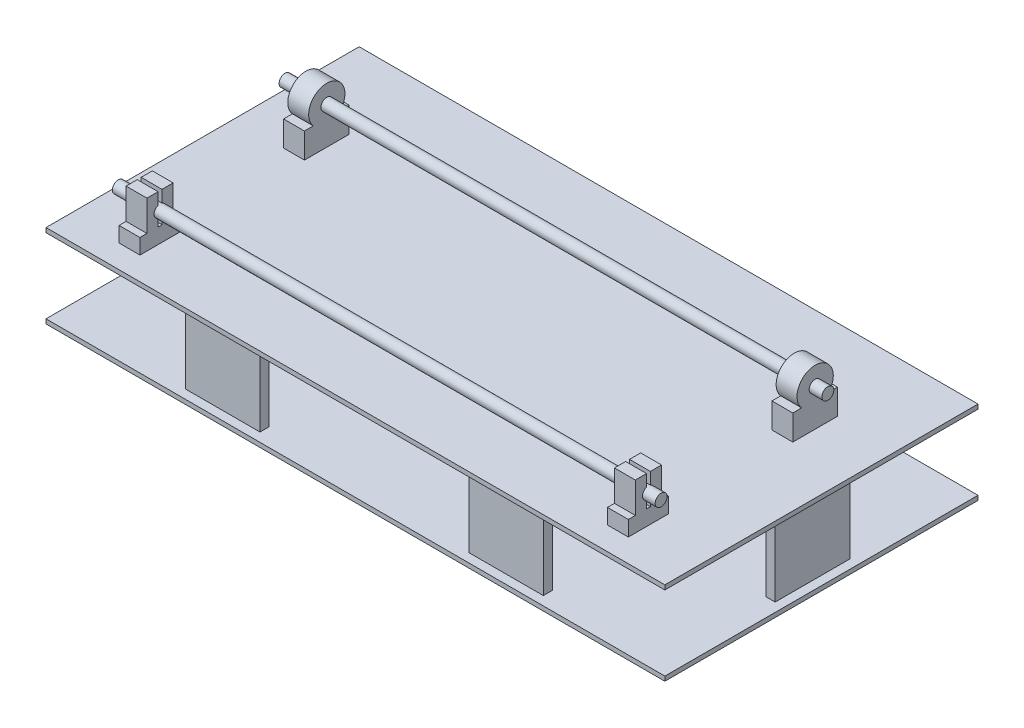
from build123d import *

# Parameters (mm, degrees)
SKETCH2_W           = 415
SKETCH2_H           = 210
BOSS_EXTRUDE1_DEPTH = 3
SKETCH3_W           = 415
SKETCH3_H           = 210
BOSS_EXTRUDE2_DEPTH = 3
BOSS_EXTRUDE3_REACH = 470.118
SKETCH4_W           = 6
SKETCH4_H           = 50
SKETCH4_W_2         = 50
SKETCH4_H_2         = 6
BOSS_EXTRUDE4_DEPTH = 14
SKETCH5_3_R         = 4
BOSS_EXTRUDE5_DEPTH = 350
SKETCH8_R           = 4
BOSS_EXTRUDE6_DEPTH = 14
SKETCH5_4_R         = 4
BOSS_EXTRUDE7_DEPTH = 14


with BuildPart() as part:
    # Sketch2 → Boss-Extrude1 (new body)
    with BuildSketch(Plane(origin=(0, 0, 0), x_dir=(1, 0, 0), z_dir=(0, 1, 0))):
        with Locations((207.5, 105)):
            Rectangle(SKETCH2_W, SKETCH2_H)
    extrude(amount=BOSS_EXTRUDE1_DEPTH)


with BuildPart() as body_2:
    # Sketch3 → Boss-Extrude2 (new body)
    with BuildSketch(Plane(origin=(0, 53, 0), x_dir=(1, 0, 0), z_dir=(0, 1, 0))):
        with Locations((207.5, 105)):
            Rectangle(SKETCH3_W, SKETCH3_H)
    extrude(amount=BOSS_EXTRUDE2_DEPTH)

    # Sketch4 → Boss-Extrude3 (add, up to next)
    with BuildSketch(Plane(origin=(0, 3, 0), x_dir=(1, 0, 0), z_dir=(0, 1, 0)), mode=Mode.PRIVATE) as boss_extrude3_sk1:
        with Locations((9, 105)):
            Rectangle(SKETCH4_W, SKETCH4_H)
    boss_extrude3_tool1 = extrude(boss_extrude3_sk1.sketch, amount=BOSS_EXTRUDE3_REACH, mode=Mode.PRIVATE) - body_2.part
    # Sketch4 → Boss-Extrude3 (add, up to next)
    with BuildSketch(Plane(origin=(0, 3, 0), x_dir=(1, 0, 0), z_dir=(0, 1, 0)), mode=Mode.PRIVATE) as boss_extrude3_sk2:
        with Locations((112.5, 9)):
            Rectangle(SKETCH4_W_2, SKETCH4_H_2)
    boss_extrude3_tool2 = extrude(boss_extrude3_sk2.sketch, amount=BOSS_EXTRUDE3_REACH, mode=Mode.PRIVATE) - body_2.part
    # Sketch4 → Boss-Extrude3 (add, up to next)
    with BuildSketch(Plane(origin=(0, 3, 0), x_dir=(1, 0, 0), z_dir=(0, 1, 0)), mode=Mode.PRIVATE) as boss_extrude3_sk3:
        with Locations((302.5, 9)):
            Rectangle(SKETCH4_W_2, SKETCH4_H_2)
    boss_extrude3_tool3 = extrude(boss_extrude3_sk3.sketch, amount=BOSS_EXTRUDE3_REACH, mode=Mode.PRIVATE) - body_2.part
    # Sketch4 → Boss-Extrude3 (add, up to next)
    with BuildSketch(Plane(origin=(0, 3, 0), x_dir=(1, 0, 0), z_dir=(0, 1, 0)), mode=Mode.PRIVATE) as boss_extrude3_sk4:
        with Locations((406, 105)):
            Rectangle(SKETCH4_W, SKETCH4_H)
    boss_extrude3_tool4 = extrude(boss_extrude3_sk4.sketch, amount=BOSS_EXTRUDE3_REACH, mode=Mode.PRIVATE) - body_2.part
    # Sketch4 → Boss-Extrude3 (add, up to next)
    with BuildSketch(Plane(origin=(0, 3, 0), x_dir=(1, 0, 0), z_dir=(0, 1, 0)), mode=Mode.PRIVATE) as boss_extrude3_sk5:
        with Locations((302.5, 201)):
            Rectangle(SKETCH4_W_2, SKETCH4_H_2)
    boss_extrude3_tool5 = extrude(boss_extrude3_sk5.sketch, amount=BOSS_EXTRUDE3_REACH, mode=Mode.PRIVATE) - body_2.part
    # Sketch4 → Boss-Extrude3 (add, up to next)
    with BuildSketch(Plane(origin=(0, 3, 0), x_dir=(1, 0, 0), z_dir=(0, 1, 0)), mode=Mode.PRIVATE) as boss_extrude3_sk6:
        with Locations((112.5, 201)):
            Rectangle(SKETCH4_W_2, SKETCH4_H_2)
    boss_extrude3_tool6 = extrude(boss_extrude3_sk6.sketch, amount=BOSS_EXTRUDE3_REACH, mode=Mode.PRIVATE) - body_2.part

    add(part.part)  # Boss-Extrude3 merges part
    add(boss_extrude3_tool1.solids().sort_by_distance((9, 3, -105))[0])
    add(boss_extrude3_tool2.solids().sort_by_distance((112.5, 3, -9))[0])
    add(boss_extrude3_tool3.solids().sort_by_distance((302.5, 3, -9))[0])
    add(boss_extrude3_tool4.solids().sort_by_distance((406, 3, -105))[0])
    add(boss_extrude3_tool5.solids().sort_by_distance((302.5, 3, -201))[0])
    add(boss_extrude3_tool6.solids().sort_by_distance((112.5, 3, -201))[0])

    # Sketch5 → Boss-Extrude4 (add)
    with BuildSketch(Plane.ZY.offset(-33.5)):
        with BuildLine():
            Line((-20.2, 66.220460186), (-20.2, 86.719329946))
            Line((-20.2, 86.719329946), (-27.7, 86.719329946))
            Line((-27.7, 86.719329946), (-27.7, 78.782856064))
            ThreePointArc((-27.7, 78.782856064), (-25, 75), (-27.7, 71.217143936))
            Line((-27.7, 71.217143936), (-27.7, 66.220460186))
            Line((-27.7, 66.220460186), (-30.3, 66.220460186))
            Line((-30.3, 66.220460186), (-30.3, 71.217143936))
            ThreePointArc((-30.3, 71.217143936), (-33, 75), (-30.3, 78.782856064))
            Line((-30.3, 78.782856064), (-30.3, 86.780809456))
            Line((-30.3, 86.780809456), (-37.8, 86.780809456))
            Line((-37.8, 86.780809456), (-37.8, 66.220460186))
            Line((-37.8, 66.220460186), (-42.5, 66.220460186))
            Line((-42.5, 66.220460186), (-42.5, 56))
            Line((-42.5, 56), (-15.5, 56))
            Line((-15.5, 56), (-15.5, 66.220460186))
            Line((-15.5, 66.220460186), (-20.2, 66.220460186))
        make_face()
        with BuildLine():
            Line((-149.888097116, 72.9128735), (-155.8, 72.9128735))
            Line((-155.8, 72.9128735), (-155.8, 56))
            Line((-155.8, 56), (-125.8, 56))
            Line((-125.8, 56), (-125.8, 72.9128735))
            Line((-125.8, 72.9128735), (-131.711902884, 72.9128735))
            ThreePointArc((-131.711902884, 72.9128735), (-140.8, 93.165324665), (-149.888097116, 72.9128735))
        make_face()
    extrude(amount=-BOSS_EXTRUDE4_DEPTH)

    # Sketch5_3 → Boss-Extrude5 (add)
    with BuildSketch(Plane.ZY.offset(-33.5)):
        with Locations((-29, 75)):
            Circle(SKETCH5_3_R)
        with Locations((-140.8, 81)):
            Circle(SKETCH5_3_R)
    extrude(amount=-BOSS_EXTRUDE5_DEPTH)

    # Sketch8 → Boss-Extrude6 (add)
    # profile 1 of 2: a face of its own
    with BuildSketch(Plane(origin=(361, 0, 0), x_dir=(0, 0, -1), z_dir=(1, 0, 0))):
        with BuildLine():
            Line((37.8, 66.220460186), (37.8, 86.719329946))
            Line((37.8, 86.719329946), (30.3, 86.719329946))
            Line((30.3, 86.719329946), (30.3, 78.782856064))
            ThreePointArc((30.3, 78.782856064), (33, 75), (30.3, 71.217143936))
            Line((30.3, 71.217143936), (30.3, 66.220460186))
            Line((30.3, 66.220460186), (27.7, 66.220460186))
            Line((27.7, 66.220460186), (27.7, 86.780809456))
            Line((27.7, 86.780809456), (20.2, 86.780809456))
            Line((20.2, 86.780809456), (20.2, 66.220460186))
            Line((20.2, 66.220460186), (15.5, 66.220460186))
            Line((15.5, 66.220460186), (15.5, 56))
            Line((15.5, 56), (42.5, 56))
            Line((42.5, 56), (42.5, 66.220460186))
            Line((42.5, 66.220460186), (37.8, 66.220460186))
        make_face()
    # profile 2 of 2: a face of its own
    with BuildSketch(Plane(origin=(361, 0, 0), x_dir=(0, 0, -1), z_dir=(1, 0, 0))):
        with BuildLine():
            Line((131.711902884, 72.9128735), (125.8, 72.9128735))
            Line((125.8, 72.9128735), (125.8, 56))
            Line((125.8, 56), (155.8, 56))
            Line((155.8, 56), (155.8, 72.9128735))
            Line((155.8, 72.9128735), (149.888097116, 72.9128735))
            ThreePointArc((149.888097116, 72.9128735), (140.8, 93.165324665), (131.711902884, 72.9128735))
        make_face()
        with Locations((140.8, 81)):
            Circle(SKETCH8_R, mode=Mode.SUBTRACT)
    extrude(amount=BOSS_EXTRUDE6_DEPTH)

    # Sketch5_4 → Boss-Extrude7 (add)
    with BuildSketch(Plane.ZY.offset(-33.5)):
        with Locations((-29, 75)):
            Circle(SKETCH5_4_R)
        with Locations((-140.8, 81)):
            Circle(SKETCH5_4_R)
    extrude(amount=BOSS_EXTRUDE7_DEPTH)


solid = body_2.part
